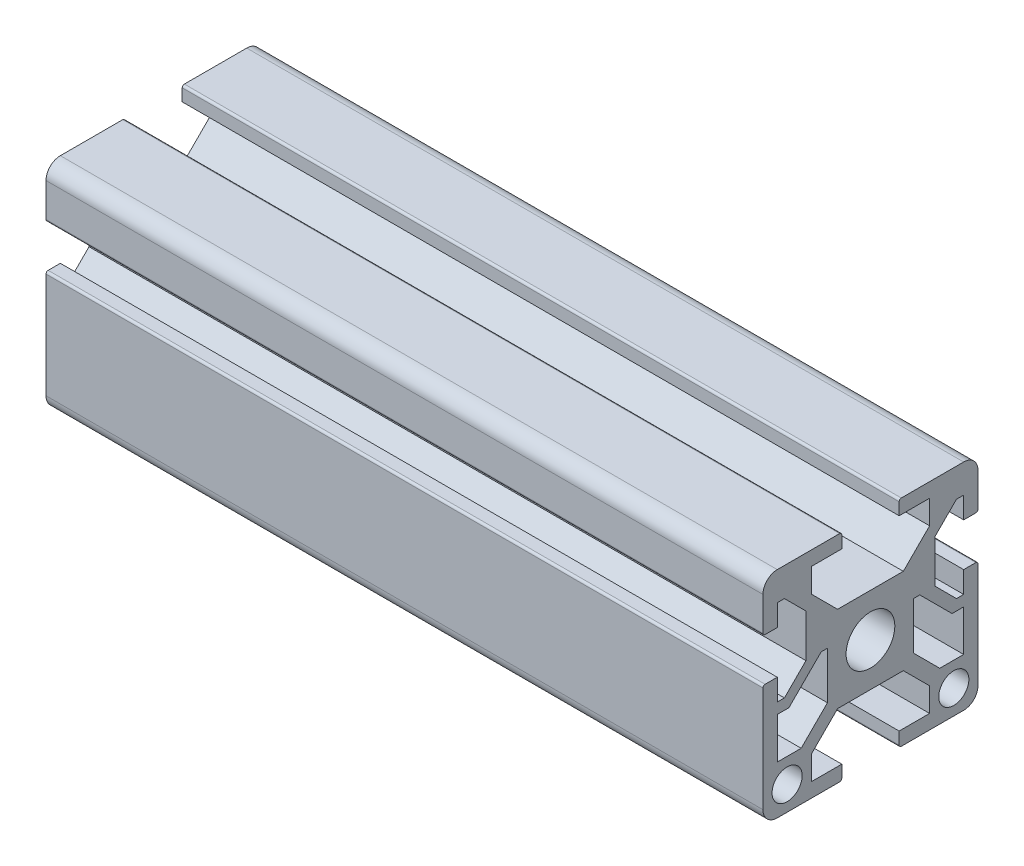
from build123d import *

# Parameters (mm, degrees)
SKETCH1_R           = 3.4
SKETCH1_R_2         = 2.1
BOSS_EXTRUDE1_DEPTH = 100


with BuildPart() as part:
    # Sketch1 → Boss-Extrude1 (new body)
    with BuildSketch(Plane(origin=(0, 0, 0), x_dir=(0, 0, -1), z_dir=(1, 0, 0))):
        with BuildLine():
            Line((-15, 1.7), (-15, -13))
            ThreePointArc((-15, -13), (-14.414213562, -14.414213562), (-13, -15))
            Line((-13, -15), (-4.3, -15))
            ThreePointArc((-4.3, -15), (-4.087867966, -14.912132034), (-4, -14.7))
            Line((-4, -14.7), (-4, -13))
            Line((-4, -13), (-8.25, -13))
            Line((-8.25, -13), (-8.25, -9.664213562))
            Line((-8.25, -9.664213562), (-4.585786438, -6))
            Line((-4.585786438, -6), (4.585786438, -6))
            Line((4.585786438, -6), (8.25, -9.664213562))
            Line((8.25, -9.664213562), (8.25, -13))
            Line((8.25, -13), (4, -13))
            Line((4, -13), (4, -14.7))
            ThreePointArc((4, -14.7), (4.087867966, -14.912132034), (4.3, -15))
            Line((4.3, -15), (13, -15))
            ThreePointArc((13, -15), (14.414213562, -14.414213562), (15, -13))
            Line((15, -13), (15, 1.7))
            ThreePointArc((15, 1.7), (14.912132034, 1.912132034), (14.7, 2))
            Line((14.7, 2), (13, 2))
            Line((13, 2), (13, -1))
            Line((13, -1), (12, -1))
            Line((12, -1), (9, 2))
            Line((9, 2), (9, 8))
            Line((9, 8), (12, 11))
            Line((12, 11), (13, 11))
            Line((13, 11), (13, 8))
            Line((13, 8), (14.7, 8))
            ThreePointArc((14.7, 8), (14.912132034, 8.087867966), (15, 8.3))
            Line((15, 8.3), (15, 13))
            ThreePointArc((15, 13), (14.414213562, 14.414213562), (13, 15))
            Line((13, 15), (4.3, 15))
            ThreePointArc((4.3, 15), (4.087867966, 14.912132034), (4, 14.7))
            Line((4, 14.7), (4, 13))
            Line((4, 13), (8.25, 13))
            Line((8.25, 13), (8.25, 9.664213562))
            Line((8.25, 9.664213562), (4.585786438, 6))
            Line((4.585786438, 6), (-4.585786438, 6))
            Line((-4.585786438, 6), (-8.25, 9.664213562))
            Line((-8.25, 9.664213562), (-8.25, 13))
            Line((-8.25, 13), (-4, 13))
            Line((-4, 13), (-4, 14.7))
            ThreePointArc((-4, 14.7), (-4.087867966, 14.912132034), (-4.3, 15))
            Line((-4.3, 15), (-13, 15))
            ThreePointArc((-13, 15), (-14.414213562, 14.414213562), (-15, 13))
            Line((-15, 13), (-15, 8.3))
            ThreePointArc((-15, 8.3), (-14.912132034, 8.087867966), (-14.7, 8))
            Line((-14.7, 8), (-13, 8))
            Line((-13, 8), (-13, 11))
            Line((-13, 11), (-12, 11))
            Line((-12, 11), (-9, 8))
            Line((-9, 8), (-9, 2))
            Line((-9, 2), (-12, -1))
            Line((-12, -1), (-13, -1))
            Line((-13, -1), (-13, 2))
            Line((-13, 2), (-14.7, 2))
            ThreePointArc((-14.7, 2), (-14.912132034, 1.912132034), (-15, 1.7))
        make_face()
        Circle(SKETCH1_R, mode=Mode.SUBTRACT)
        with Locations((-11.625, -11.625)):
            Circle(SKETCH1_R_2, mode=Mode.SUBTRACT)
        with Locations((11.625, -11.625)):
            Circle(SKETCH1_R_2, mode=Mode.SUBTRACT)
        Polygon((-13, -2.5), (-13, -8.25), (-9.664213562, -8.25), (-6, -4.585786438), (-6, 2), (-6.878679656, 2), (-11.378679656, -2.5), align=None, mode=Mode.SUBTRACT)
        Polygon((6, 2), (6, -4.585786438), (9.664213562, -8.25), (13, -8.25), (13, -2.5), (11.378679656, -2.5), (6.878679656, 2), align=None, mode=Mode.SUBTRACT)
    extrude(amount=BOSS_EXTRUDE1_DEPTH)


solid = part.part
